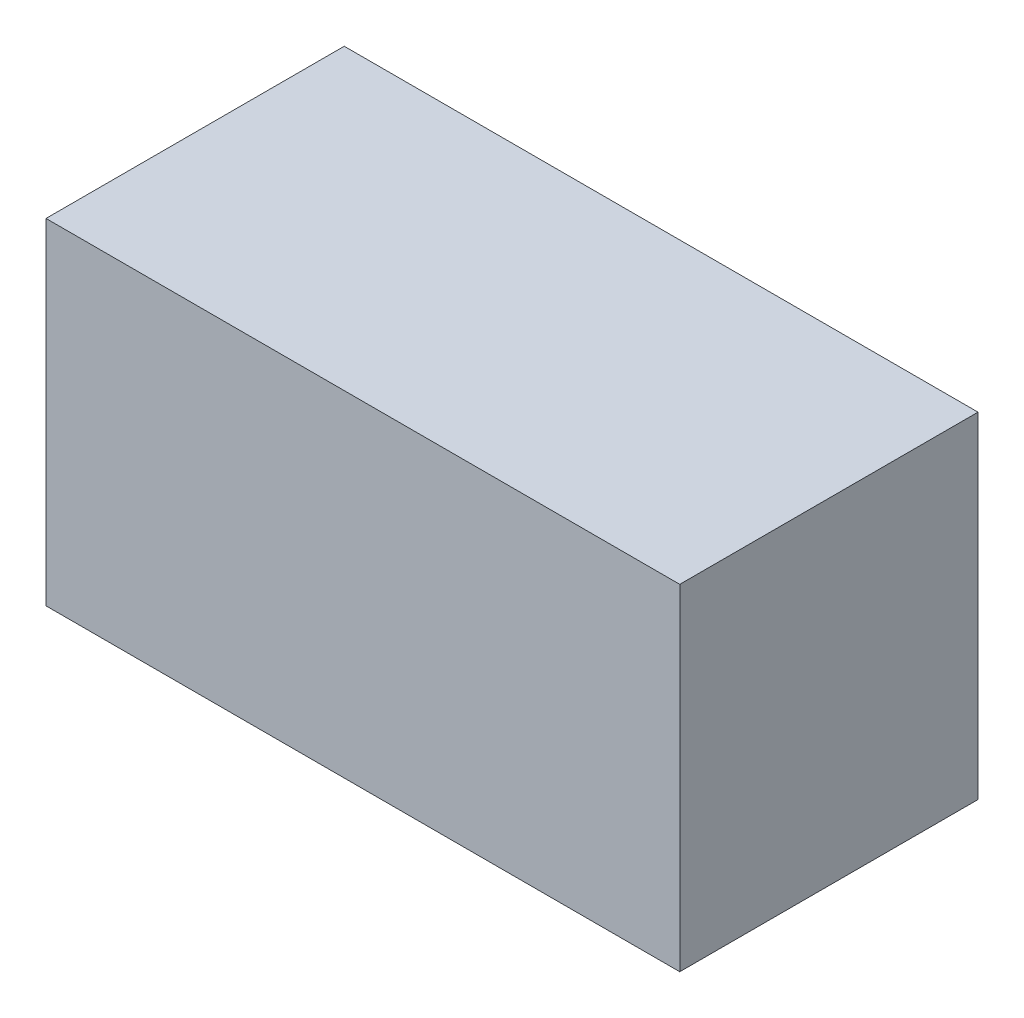
from build123d import *

# Parameters (mm, degrees)
BODY_2_W   = 17
BODY_2_H   = 9
BODY_DEPTH = 4


with BuildPart() as part:
    # body 2 → body (new body, symmetric)
    with BuildSketch(Plane.XY):
        Rectangle(BODY_2_W, BODY_2_H)
    extrude(amount=BODY_DEPTH, both=True)


solid = part.part
